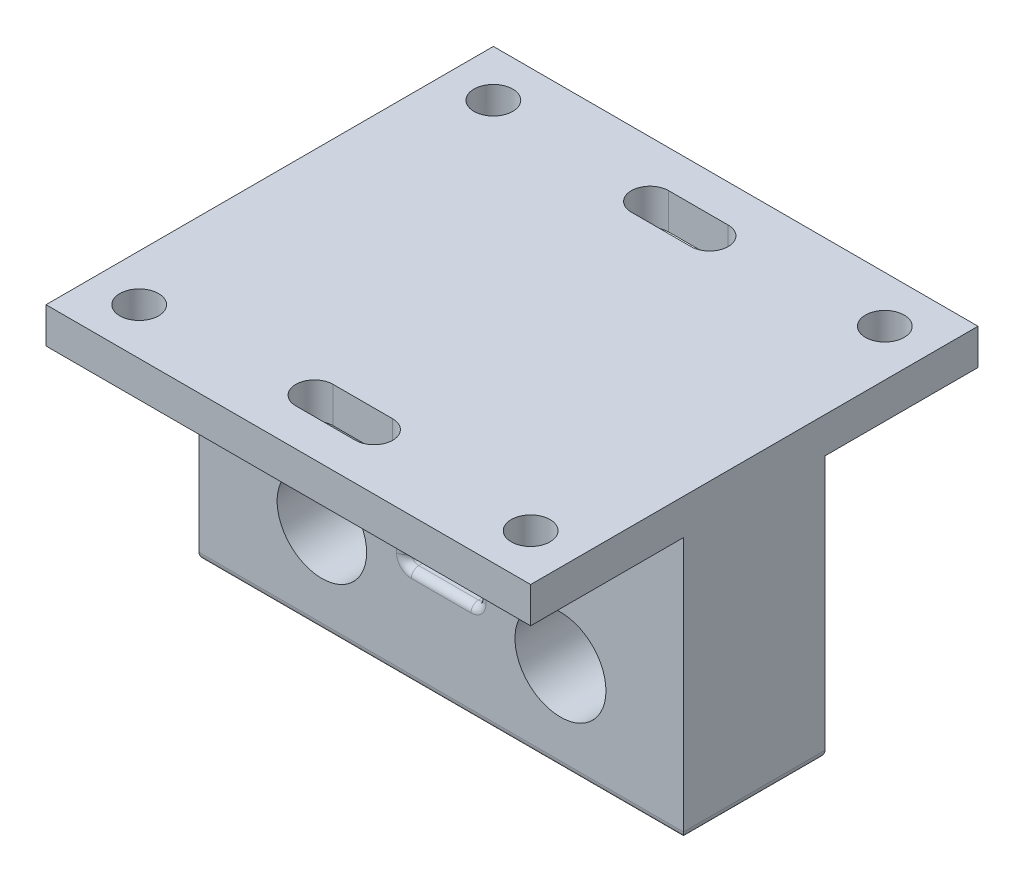
from build123d import *

# Parameters (mm, degrees)
SKETCH1_W           = 65
SKETCH1_H           = 40
SKETCH1_R           = 6
SKETCH1_R_2         = 6.1
BOSS_EXTRUDE1_DEPTH = 19
SKETCH4_W           = 65
SKETCH4_H           = 14.8
BOSS_EXTRUDE2_DEPTH = 35
SKETCH6_W           = 10
SKETCH6_H           = 12
CUT_EXTRUDE1_DEPTH  = 45.5
CUT_EXTRUDE3_DEPTH  = 41
FILLET1_R           = 1
SKETCH9_W           = 65
SKETCH9_H           = 14.8
CUT_EXTRUDE4_DEPTH  = 5
SKETCH10_W          = 65
SKETCH10_H          = 14.8
CUT_EXTRUDE5_DEPTH  = 5
SKETCH11_R          = 2.6
CUT_EXTRUDE6_DEPTH  = 41
CUT_EXTRUDE7_DEPTH  = 10


with BuildPart() as part:
    # Sketch1 → Boss-Extrude1 (new body)
    with BuildSketch(Plane.XY):
        with Locations((14, 7.8)):
            Rectangle(SKETCH1_W, SKETCH1_H)
        with Locations((-2, 0)):
            Circle(SKETCH1_R, mode=Mode.SUBTRACT)
        with Locations((30, 0)):
            Circle(SKETCH1_R_2, mode=Mode.SUBTRACT)
    extrude(amount=-BOSS_EXTRUDE1_DEPTH)

    # Sketch4 → Boss-Extrude2 (add, symmetric)
    with BuildSketch(Plane.XY.offset(-9.5)):
        with Locations((14, 20.4)):
            Rectangle(SKETCH4_W, SKETCH4_H)
    extrude(amount=BOSS_EXTRUDE2_DEPTH, both=True)

    # Sketch6 → Cut-Extrude1 (cut, through all)
    with BuildSketch(Plane.XY):
        with Locations((14, 7)):
            Rectangle(SKETCH6_W, SKETCH6_H)
    extrude(amount=-CUT_EXTRUDE1_DEPTH, mode=Mode.SUBTRACT)

    # Sketch8 → Cut-Extrude3 (cut, through all)
    with BuildSketch(Plane(origin=(0, 27.8, 0), x_dir=(1, 0, 0), z_dir=(0, 1, 0))):
        with BuildLine():
            Line((18, 29.5), (10, 29.5))
            ThreePointArc((10, 29.5), (7.5, 32), (10, 34.5))
            Line((10, 34.5), (18, 34.5))
            ThreePointArc((18, 34.5), (20.5, 32), (18, 29.5))
        make_face()
        with BuildLine():
            Line((18, -10.5), (10, -10.5))
            ThreePointArc((10, -10.5), (7.5, -13), (10, -15.5))
            Line((10, -15.5), (18, -15.5))
            ThreePointArc((18, -15.5), (20.5, -13), (18, -10.5))
        make_face()
    extrude(amount=-CUT_EXTRUDE3_DEPTH, mode=Mode.SUBTRACT)

    # Fillet1
    fillet1_edges = [part.edges().sort_by_distance(p)[0] for p in [
        (14, 1, -19),
        (9, 7, -19),
        (19, 7, -19),
        (9, 1, -9.5),
        (19, 1, -9.5),
        (9, 7, 0),
        (14, 1, 0),
        (19, 7, 0),
        (14, -12.2, 0),
        (46.5, -12.2, -9.5),
        (-18.5, -12.2, -9.5),
        (14, -12.2, -19),
    ]]
    fillet(fillet1_edges, radius=FILLET1_R)

    # Sketch9 → Cut-Extrude4 (cut)
    with BuildSketch(Plane.XY.offset(25.5)):
        with Locations((14, 20.4)):
            Rectangle(SKETCH9_W, SKETCH9_H)
    extrude(amount=-CUT_EXTRUDE4_DEPTH, mode=Mode.SUBTRACT)

    # Sketch10 → Cut-Extrude5 (cut)
    with BuildSketch(Plane(origin=(0, 0, -44.5), x_dir=(-1, 0, 0), z_dir=(0, 0, -1))):
        with Locations((-14, 20.4)):
            Rectangle(SKETCH10_W, SKETCH10_H)
    extrude(amount=-CUT_EXTRUDE5_DEPTH, mode=Mode.SUBTRACT)

    # Sketch11 → Cut-Extrude6 (cut, through all)
    with BuildSketch(Plane(origin=(0, 27.8, 0), x_dir=(1, 0, 0), z_dir=(0, 1, 0))):
        with Locations((40.25, -14.25)):
            Circle(SKETCH11_R)
        with Locations((40.25, 33.25)):
            Circle(SKETCH11_R)
        with Locations((-12.25, 33.25)):
            Circle(SKETCH11_R)
        with Locations((-12.25, -14.25)):
            Circle(SKETCH11_R)
    extrude(amount=-CUT_EXTRUDE6_DEPTH, mode=Mode.SUBTRACT)

    # Sketch12 → Cut-Extrude7 (cut)
    with BuildSketch(Plane.XZ.offset(-13)):
        with BuildLine():
            Line((-18.5, -39.5), (46.5, -39.5))
            Line((46.5, -39.5), (46.5, -19))
            Line((46.5, -19), (20, -19))
            ThreePointArc((20, -19), (19.292893219, -18.707106781), (19, -18))
            Line((19, -18), (19, -1))
            ThreePointArc((19, -1), (19.292893219, -0.292893219), (20, 0))
            Line((20, 0), (46.5, 0))
            Line((46.5, 0), (46.5, 20.5))
            Line((46.5, 20.5), (-18.5, 20.5))
            Line((-18.5, 20.5), (-18.5, 0))
            Line((-18.5, 0), (8, 0))
            ThreePointArc((8, 0), (8.707106781, -0.292893219), (9, -1))
            Line((9, -1), (9, -18))
            ThreePointArc((9, -18), (8.707106781, -18.707106781), (8, -19))
            Line((8, -19), (-18.5, -19))
            Line((-18.5, -19), (-18.5, -39.5))
        make_face()
    extrude(amount=-CUT_EXTRUDE7_DEPTH, mode=Mode.SUBTRACT)


solid = part.part
